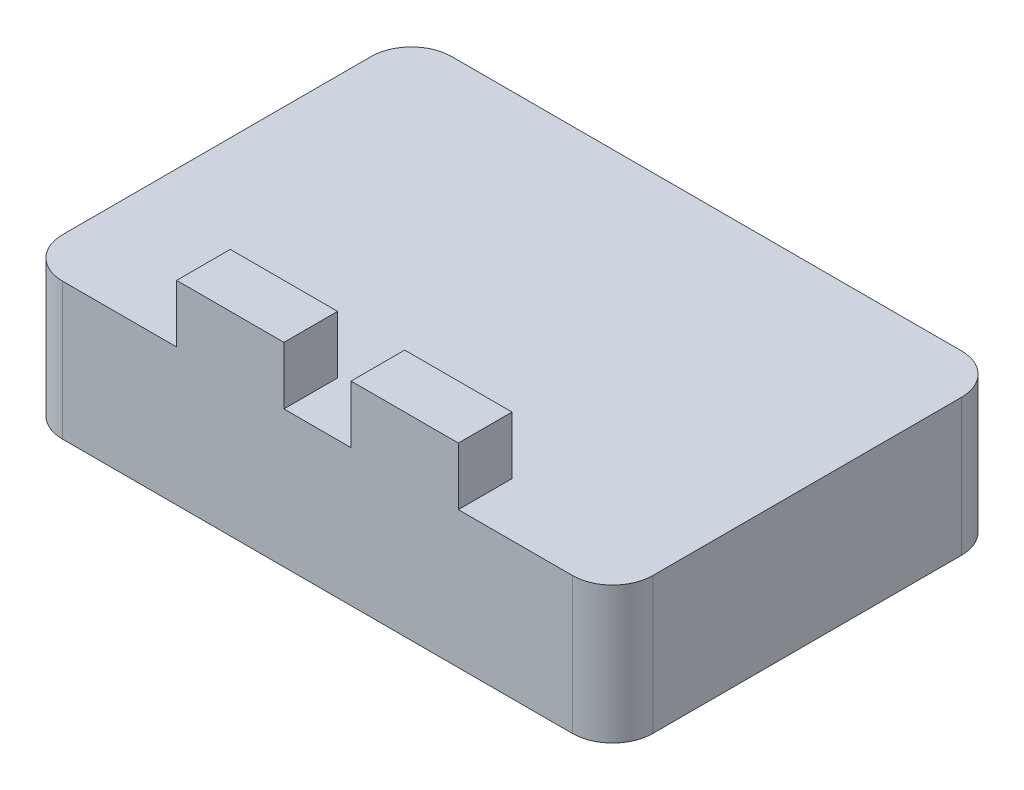
from build123d import *

# Parameters (mm, degrees)
SKETCH1_W           = 44
SKETCH1_H           = 29
BOSS_EXTRUDE1_DEPTH = 10.2
SKETCH2_W           = 8
SKETCH2_H           = 4
BOSS_EXTRUDE2_DEPTH = 4.3
FILLET1_R           = 3


with BuildPart() as part:
    # Sketch1 → Boss-Extrude1 (new body)
    with BuildSketch(Plane(origin=(0, 0, 0), x_dir=(1, 0, 0), z_dir=(0, 1, 0))):
        with Locations((22, 14.5)):
            Rectangle(SKETCH1_W, SKETCH1_H)
    extrude(amount=BOSS_EXTRUDE1_DEPTH)

    # Sketch2 → Boss-Extrude2 (add)
    with BuildSketch(Plane(origin=(0, 10.2, 0), x_dir=(1, 0, 0), z_dir=(0, 1, 0))):
        with Locations((28.5, 2)):
            Rectangle(SKETCH2_W, SKETCH2_H)
        with Locations((15.5, 2)):
            Rectangle(SKETCH2_W, SKETCH2_H)
    extrude(amount=BOSS_EXTRUDE2_DEPTH)

    # Fillet1
    fillet1_edges = [part.edges().sort_by_distance(p)[0] for p in [
        (0, 5.1, -29),
        (44, 5.1, -29),
        (44, 5.1, 0),
        (0, 5.1, 0),
    ]]
    fillet(fillet1_edges, radius=FILLET1_R)


solid = part.part
